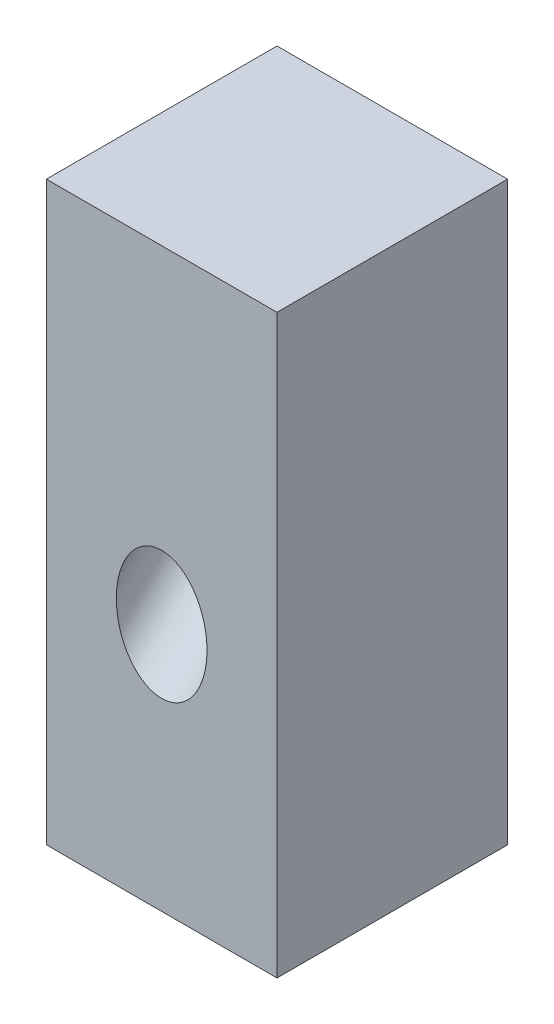
from build123d import *

# Parameters (mm, degrees)
SKETCH1_W                = 40
SKETCH1_H                = 40
BOSS_EXTRUDE1_DEPTH      = 68
BOSS_EXTRUDE1_DEPTH_BACK = 32
SKETCH4_R                = 7.825
CUT_EXTRUDE2_DEPTH       = 77.367532368
CUT_EXTRUDE2_TAPER       = -0.28


with BuildPart() as part:
    # Sketch1 → Boss-Extrude1 (new body, two sides)
    with BuildSketch(Plane(origin=(0, 0, 0), x_dir=(1, 0, 0), z_dir=(0, 1, 0))) as boss_extrude1_sk:
        with Locations((20, 20)):
            Rectangle(SKETCH1_W, SKETCH1_H)
    extrude(amount=BOSS_EXTRUDE1_DEPTH)
    extrude(boss_extrude1_sk.sketch, amount=-BOSS_EXTRUDE1_DEPTH_BACK)

    # Sketch4 → Cut-Extrude2 (cut, through all)
    with BuildSketch(Plane(origin=(0, 0, 0), x_dir=(1, 0, 0), z_dir=(0, -0.707106781, 0.707106781))):
        with Locations((20, 7.825)):
            Circle(SKETCH4_R)
    extrude(amount=-CUT_EXTRUDE2_DEPTH, taper=CUT_EXTRUDE2_TAPER, mode=Mode.SUBTRACT)


solid = part.part
